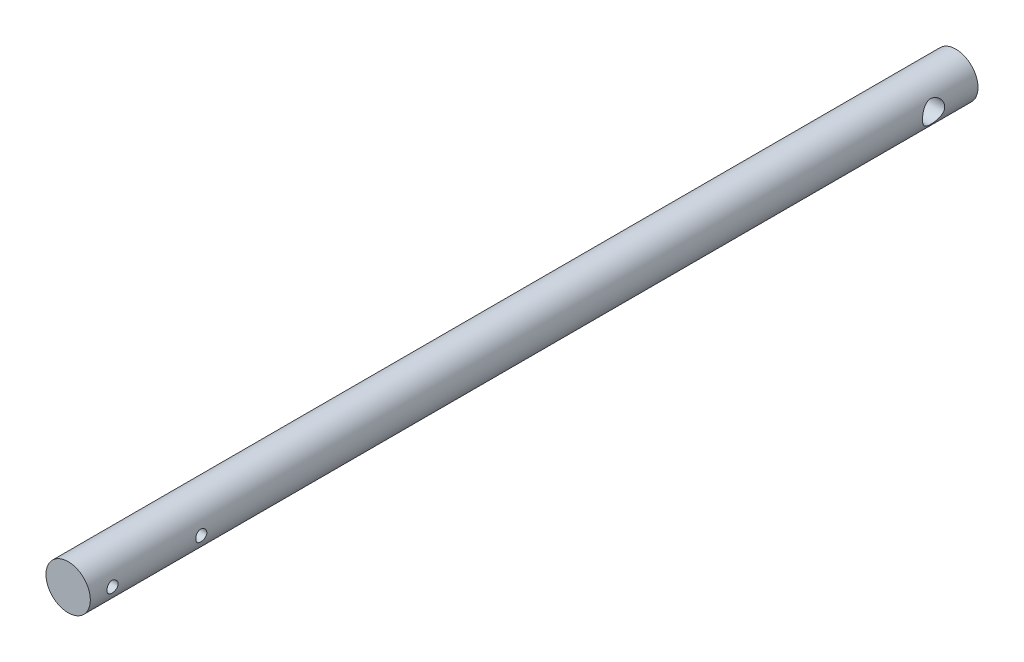
from build123d import *

# Parameters (mm, degrees)
SKETCH1_R               = 12.7
BOSS_EXTRUDE1_DEPTH     = 254
SKETCH2_R               = 3.175
SKETCH2_R_2             = 6.35
CUT_EXTRUDE1_DEPTH      = 13.7
CUT_EXTRUDE1_DEPTH_BACK = 13.7


with BuildPart() as part:
    # Sketch1 → Boss-Extrude1 (new body, symmetric)
    with BuildSketch(Plane.XY):
        Circle(SKETCH1_R)
    extrude(amount=BOSS_EXTRUDE1_DEPTH, both=True)

    # Sketch2 → Cut-Extrude1 (cut, two sides)
    with BuildSketch(Plane(origin=(0, 0, 0), x_dir=(0, 0, -1), z_dir=(1, 0, 0))) as cut_extrude1_sk:
        with Locations((-241.3, 0)):
            Circle(SKETCH2_R)
        with Locations((-190.5, 0)):
            Circle(SKETCH2_R)
        with Locations((228.6, 0)):
            Circle(SKETCH2_R_2)
    extrude(amount=CUT_EXTRUDE1_DEPTH, mode=Mode.SUBTRACT)
    extrude(cut_extrude1_sk.sketch, amount=-CUT_EXTRUDE1_DEPTH_BACK, mode=Mode.SUBTRACT)


solid = part.part
